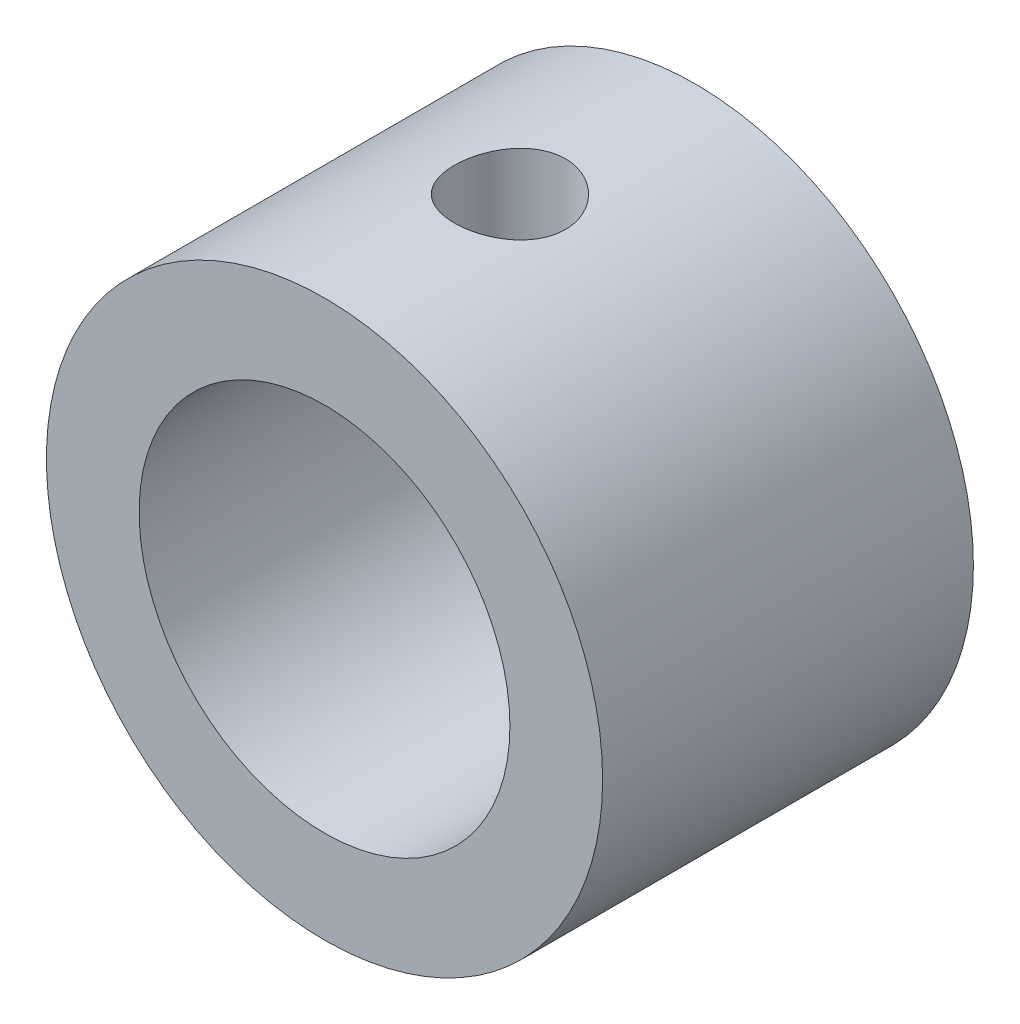
from build123d import *

# Parameters (mm, degrees)
SKETCH1_R           = 7.5
SKETCH1_R_2         = 5
BOSS_EXTRUDE1_DEPTH = 5
SKETCH2_R           = 1.5
CUT_EXTRUDE1_DEPTH  = 9


with BuildPart() as part:
    # Sketch1 → Boss-Extrude1 (new body, symmetric)
    with BuildSketch(Plane.XY):
        Circle(SKETCH1_R)
        Circle(SKETCH1_R_2, mode=Mode.SUBTRACT)
    extrude(amount=BOSS_EXTRUDE1_DEPTH, both=True)

    # Sketch2 → Cut-Extrude1 (cut)
    with BuildSketch(Plane(origin=(0, 0, 0), x_dir=(1, 0, 0), z_dir=(0, 1, 0))):
        Circle(SKETCH2_R)
    extrude(amount=CUT_EXTRUDE1_DEPTH, mode=Mode.SUBTRACT)


solid = part.part
